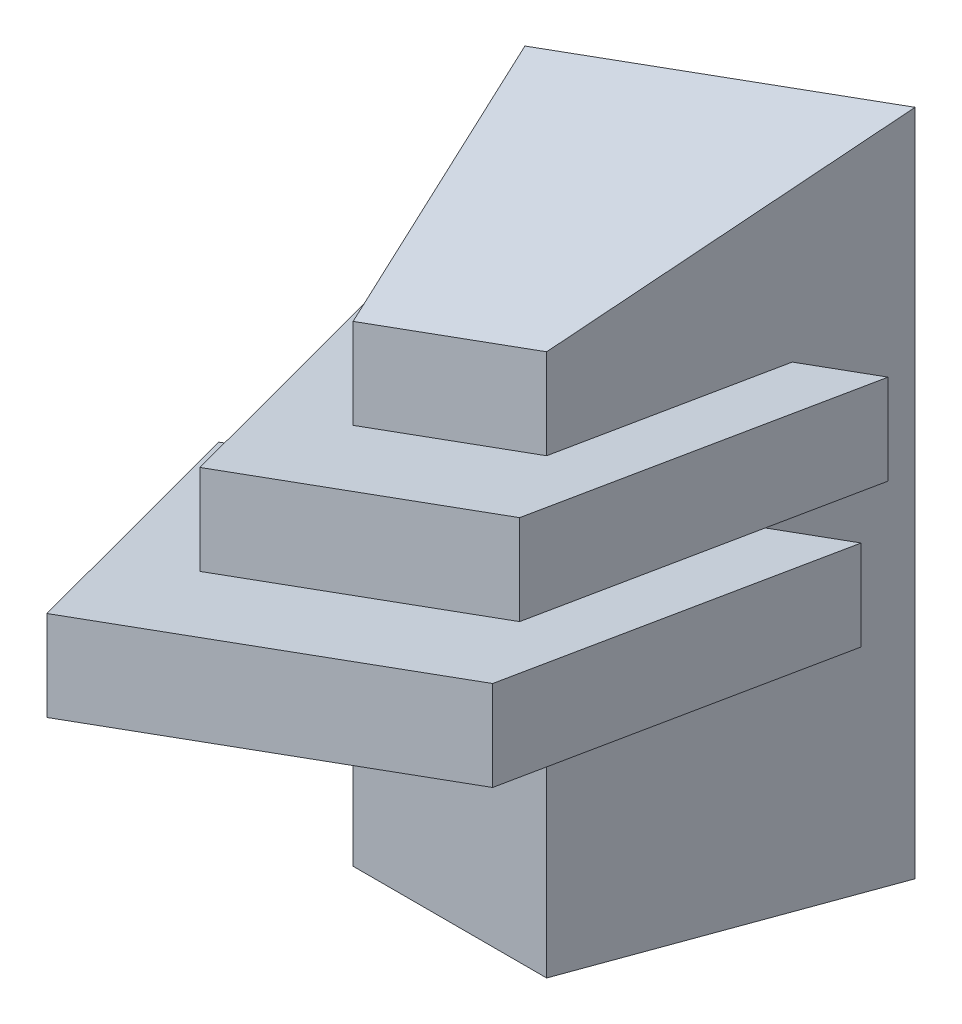
from build123d import *

# Parameters (mm, degrees)
EXTRUDE1_DEPTH     = 111.30370628
CUT_EXTRUDE1_DEPTH = 46
SKETCH4_W          = 93.704770794
SKETCH4_H          = 56.784227463
CUT_EXTRUDE2_DEPTH = 111.30370628
EXTRUDE2_DEPTH     = 111.30370628
SKETCH11_W         = 148.9717492
SKETCH11_H         = 56.952864623
CUT_EXTRUDE3_DEPTH = 60
SKETCH12_W         = 149.677776447
SKETCH12_H         = 58.364919118
CUT_EXTRUDE4_DEPTH = 80
EXTRUDE3_DEPTH     = 90
SKETCH14_W         = 111.854252755
SKETCH14_H         = 53.467616039
CUT_EXTRUDE5_DEPTH = 40
SKETCH15_W         = 126.852412542
SKETCH15_H         = 52.398263719
CUT_EXTRUDE6_DEPTH = 70


with BuildPart() as part:
    # Sketch1 → Extrude1 (new body)
    with BuildSketch(Plane(origin=(0, 0, 0), x_dir=(1, 0, 0), z_dir=(0, 1, 0))):
        Polygon((21.0062615, 30), (53.24890506, 30), (69.6275656, 75), (4.6275656, 75), align=None)
    extrude(amount=EXTRUDE1_DEPTH)

    # Sketch2 → Cut-Extrude1 (cut, through all)
    with BuildSketch(Plane.XY.offset(-30)):
        Polygon((69.6275656, 111.30370628), (4.6275656, 111.30370628), (4.6275656, 87.645641053), align=None)
    extrude(amount=-CUT_EXTRUDE1_DEPTH, mode=Mode.SUBTRACT)

    # Sketch4 → Cut-Extrude2 (cut)
    with BuildSketch(Plane(origin=(-17.842051082, 49.020632465, 16.340210822), x_dir=(0.945237473, 0.309634474, 0.103211491), z_dir=(0.326383393, -0.896731003, -0.298910334))):
        with Locations((55.789149016, -81.366436022)):
            Rectangle(SKETCH4_W, SKETCH4_H)
    extrude(amount=-CUT_EXTRUDE2_DEPTH, mode=Mode.SUBTRACT)


with BuildPart() as body_2:
    # Sketch6 → Extrude2 (new body)
    with BuildSketch(Plane(origin=(0, 0, 0), x_dir=(1, 0, 0), z_dir=(0, 1, 0))):
        Polygon((-16.3786959, 45), (90.633791747, 45), (74.255131207, 0), (0, 0), align=None)
    extrude(amount=EXTRUDE2_DEPTH)

    # Sketch11 → Cut-Extrude3 (cut)
    with BuildSketch(Plane(origin=(-8.343815422, 22.924444463, 0), x_dir=(-0.939692621, -0.342020143, 0), z_dir=(-0.342020143, 0.939692621, 0))):
        with Locations((-52.925432522, -24.484117378)):
            Rectangle(SKETCH11_W, SKETCH11_H)
    extrude(amount=-CUT_EXTRUDE3_DEPTH, mode=Mode.SUBTRACT)

    # Sketch12 → Cut-Extrude4 (cut)
    with BuildSketch(Plane(origin=(-13.164722494, 36.169777787, 0), x_dir=(-0.939692621, -0.342020143, 0), z_dir=(-0.342020143, 0.939692621, 0))):
        with Locations((-55.867212719, -21.895350804)):
            Rectangle(SKETCH12_W, SKETCH12_H)
    extrude(amount=CUT_EXTRUDE4_DEPTH, mode=Mode.SUBTRACT)


with BuildPart() as body_3:
    # Sketch13 → Extrude3 (new body)
    with BuildSketch(Plane(origin=(0, 0, 0), x_dir=(1, 0, 0), z_dir=(0, 1, 0))):
        Polygon((-5.875590582, 60), (80.130678674, 60), (63.752018134, 15), (10.503105318, 15), align=None)
    extrude(amount=EXTRUDE3_DEPTH)

    # Sketch14 → Cut-Extrude5 (cut)
    with BuildSketch(Plane(origin=(-17.985629567, 49.41511111, 0), x_dir=(-0.939692621, -0.342020143, 0), z_dir=(-0.342020143, 0.939692621, 0))):
        with Locations((-60.555614074, -40.410095572)):
            Rectangle(SKETCH14_W, SKETCH14_H)
    extrude(amount=CUT_EXTRUDE5_DEPTH, mode=Mode.SUBTRACT)

    # Sketch15 → Cut-Extrude6 (cut)
    with BuildSketch(Plane(origin=(-13.164722494, 36.169777787, 0), x_dir=(-0.939692621, -0.342020143, 0), z_dir=(-0.342020143, 0.939692621, 0))):
        with Locations((-55.409109287, -38.592196628)):
            Rectangle(SKETCH15_W, SKETCH15_H)
    extrude(amount=-CUT_EXTRUDE6_DEPTH, mode=Mode.SUBTRACT)


solid = Compound([part.part, body_2.part, body_3.part])
